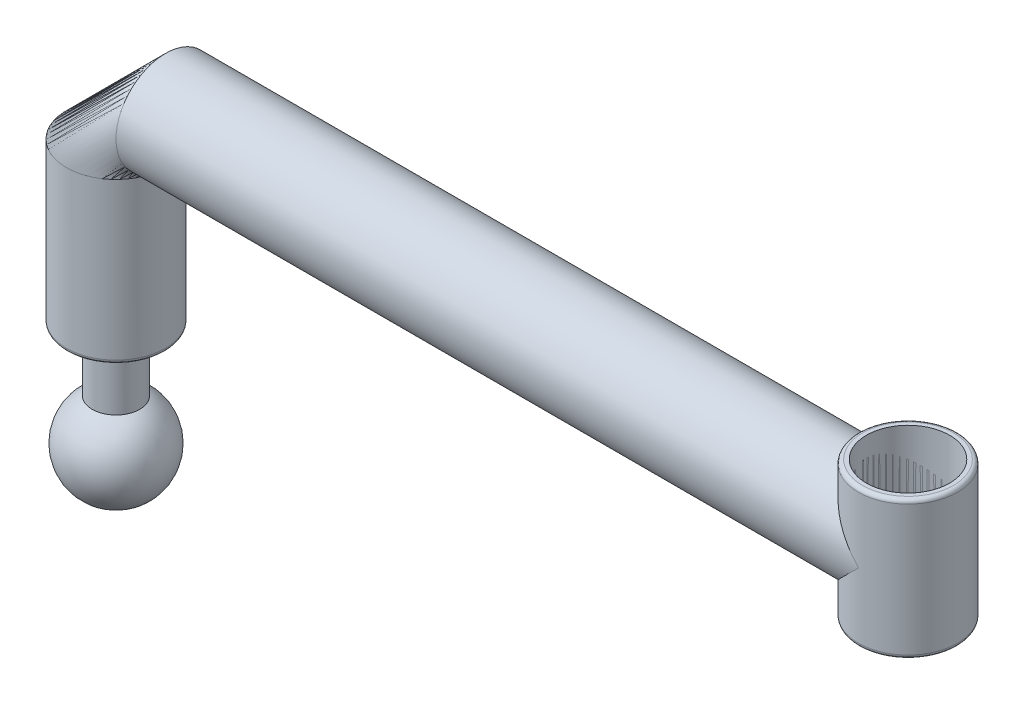
from build123d import *

# Parameters (mm, degrees)
SKETCH_2_R          = 6
EXTRUDE_1_DEPTH     = 26
SKETCH_3_R          = 12.5
SKETCH_6_R          = 12.5
SHELL_1_T           = -2
SKETCH_7_R          = 10.5
CUT_EXTRUDE_1_DEPTH = 226.860023029
FILLET_1_R          = 1
FILLET_2_R          = 1


with BuildPart() as part:
    # 草圖1 → 旋轉1 (revolve)
    with BuildSketch(Plane.XY):
        with BuildLine():
            Line((0, 12), (0, -12))
            ThreePointArc((0, -12), (12, 0), (0, 12))
        make_face()
    revolve(axis=Axis((0, 12, 0), (0, -1, 0)))

    # 草圖2 → 填料-伸長1 (add)
    with BuildSketch(Plane(origin=(0, 0, 0), x_dir=(1, 0, 0), z_dir=(0, 1, 0))):
        with Locations(Location((0, 0, 0), (0, 0, 90))):
            Circle(SKETCH_2_R)
    extrude(amount=EXTRUDE_1_DEPTH)


with BuildPart() as body_2:
    # 掃出1: sweep along a path in 草圖4
    with BuildLine(Plane.XY) as sweep_1_path:
        Line((0, 26), (0, 66.5))
        ThreePointArc((0, 66.5), (3.661165235, 75.338834765), (12.5, 79))
        Line((12.5, 79), (200, 79))
    # 草圖3 → 掃出1 (sweep)
    with BuildSketch(Plane(origin=(0, 26, 0), x_dir=(1, 0, 0), z_dir=(0, 1, 0))):
        Circle(SKETCH_3_R)
    sweep(path=sweep_1_path.line)

    # 草圖7 → 除料-伸長1 (cut, through all)
    with BuildSketch(Plane(origin=(0, 63.5, 0), x_dir=(1, 0, 0), z_dir=(0, 1, 0))):
        with Locations(Location((200, 0, 0), (0, 0, 270))):
            Circle(SKETCH_7_R)
    extrude(amount=CUT_EXTRUDE_1_DEPTH, mode=Mode.SUBTRACT)

    # 圓角1
    fillet_1_edges = [body_2.edges().sort_by_distance(p)[0] for p in [
        (-12.5, 26, 0),
    ]]
    fillet(fillet_1_edges, radius=FILLET_1_R)


with BuildPart() as body_3:
    # 掃出2: sweep along a path in 草圖5
    with BuildLine(Plane.XY) as sweep_2_path:
        Line((200, 61.5), (200, 79))
        Line((200, 79), (200, 96.5))
    # 草圖6 → 掃出2 (sweep)
    with BuildSketch(Plane(origin=(0, 96.5, 0), x_dir=(1, 0, 0), z_dir=(0, 1, 0))):
        with Locations((200, 0)):
            Circle(SKETCH_6_R)
    sweep(path=sweep_2_path.line)

    # 薄殼1
    shell_1_openings = [body_3.faces().sort_by_distance(p)[0] for p in [
        (200, 96.5, 0),
    ]]
    offset(amount=SHELL_1_T, openings=shell_1_openings, kind=Kind.INTERSECTION)

    # 圓角2
    fillet_2_edges = [body_3.edges().sort_by_distance(p)[0] for p in [
        (187.5, 96.5, 0),
        (187.5, 61.5, 0),
    ]]
    fillet(fillet_2_edges, radius=FILLET_2_R)


solid = Compound([part.part, body_2.part, body_3.part])
